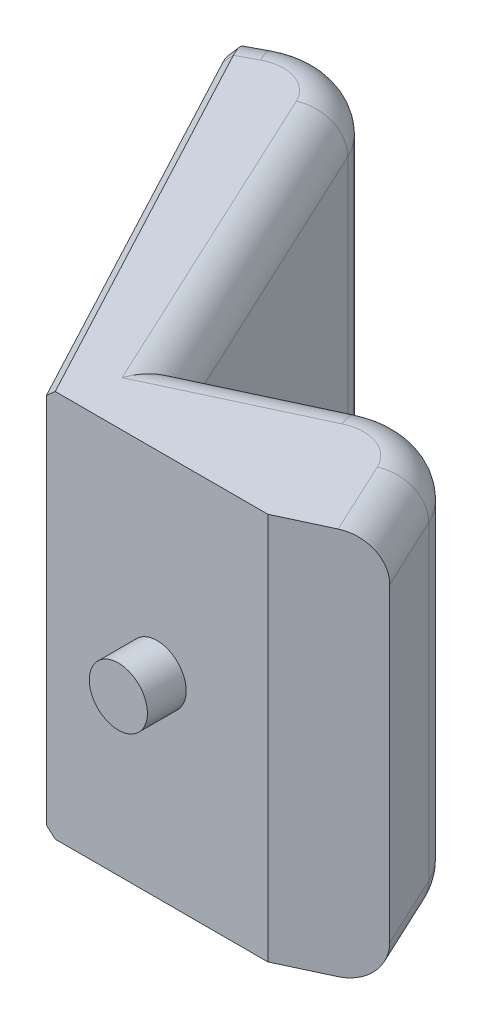
from build123d import *

# Parameters (mm, degrees)
BOSS_EXTRUDE1_DEPTH = 50
SKETCH2_R           = 7.5
BOSS_EXTRUDE2_DEPTH = 10
FILLET1_R           = 10
CHAMFER1_SIZE       = 2


with BuildPart() as part:
    # Sketch1 → Boss-Extrude1 (new body, symmetric)
    with BuildSketch(Plane(origin=(0, 0, 0), x_dir=(1, 0, 0), z_dir=(0, 1, 0))):
        with BuildLine():
            Line((-56.319582284, 105.962751245), (0, 0))
            Line((0, 0), (57.1, 0))
            Line((57.1, 0), (78.545069205, 10))
            Line((78.545069205, 10), (69.74571647, 28.870272836))
            ThreePointArc((69.74571647, 28.870272836), (58.104205428, 39.537752317), (42.329366947, 38.849007995))
            Line((42.329366947, 38.849007995), (12.63007346, 25))
            Line((12.63007346, 25), (-22.414079104, 100.152427697))
            ThreePointArc((-22.414079104, 100.152427697), (-34.192619771, 110.666026263), (-49.926831892, 109.360521003))
            Line((-49.926831892, 109.360521003), (-56.319582284, 105.962751245))
        make_face()
    extrude(amount=BOSS_EXTRUDE1_DEPTH, both=True)

    # Sketch2 → Boss-Extrude2 (add)
    with BuildSketch(Plane.XY):
        with Locations((28.55, 0)):
            Circle(SKETCH2_R)
    extrude(amount=BOSS_EXTRUDE2_DEPTH)

    # Fillet1
    fillet1_edges = [part.edges().sort_by_distance(p)[0] for p in [
        (74.145392838, -50, -19.435136418),
        (-53.123207088, -50, -107.661636124),
        (74.145392838, 50, -19.435136418),
        (58.104205428, 50, -39.537752317),
        (27.479720204, 50, -31.924503997),
        (-4.892002822, 50, -62.576213849),
        (-34.192619771, 50, -110.666026263),
        (-53.123207088, 50, -107.661636124),
        (-34.192619771, -50, -110.666026263),
        (-4.892002822, -50, -62.576213849),
        (27.479720204, -50, -31.924503997),
        (58.104205428, -50, -39.537752317),
    ]]
    fillet(fillet1_edges, radius=FILLET1_R)

    # Chamfer1
    chamfer1_edges = [part.edges().sort_by_distance(p)[0] for p in [
        (-56.319582284, 0, -105.962751245),
        (-25.81314188, -50, -48.566260987),
        (-25.81314188, 50, -48.566260987),
        (-54.944946973, 47.071067812, -103.376436971),
        (-54.944946973, -47.071067812, -103.376436971),
    ]]
    chamfer(chamfer1_edges, length=CHAMFER1_SIZE)


solid = part.part
